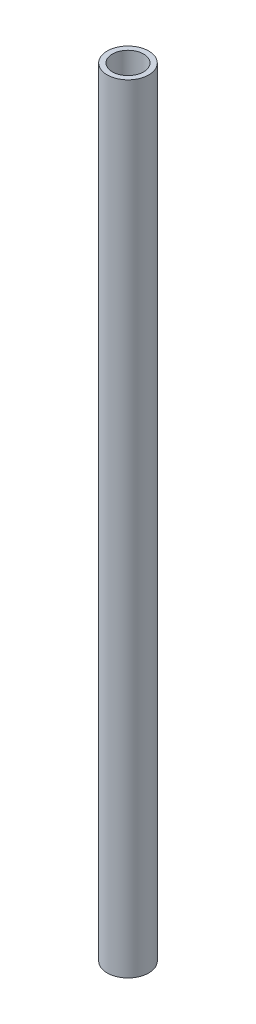
from build123d import *

# Parameters (mm, degrees)
SKETCH1_R           = 8
SKETCH1_R_2         = 6
BOSS_EXTRUDE1_DEPTH = 300


with BuildPart() as part:
    # Sketch1 → Boss-Extrude1 (new body)
    with BuildSketch(Plane(origin=(0, 0, 0), x_dir=(1, 0, 0), z_dir=(0, 1, 0))):
        Circle(SKETCH1_R)
        Circle(SKETCH1_R_2, mode=Mode.SUBTRACT)
    extrude(amount=BOSS_EXTRUDE1_DEPTH)


solid = part.part
